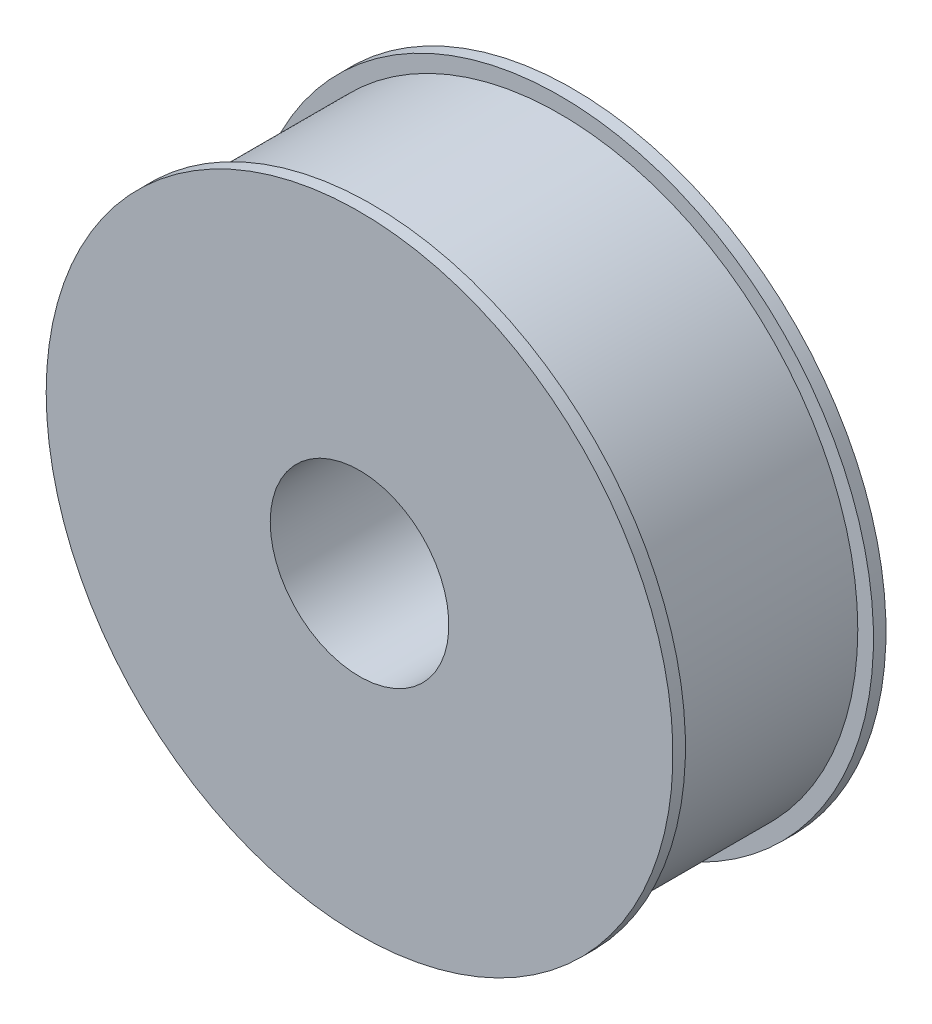
from build123d import *


with BuildPart() as part:
    # Sketch1 → Revolve1 (revolve)
    with BuildSketch(Plane.XZ):
        Polygon((28.5, 34), (28.5, -34), (100, -34), (100, -30), (95, -30), (95, 30), (100, 30), (100, 34), align=None)
    revolve(axis=Axis((0, 0, 34), (0, 0, -1)))


solid = part.part
